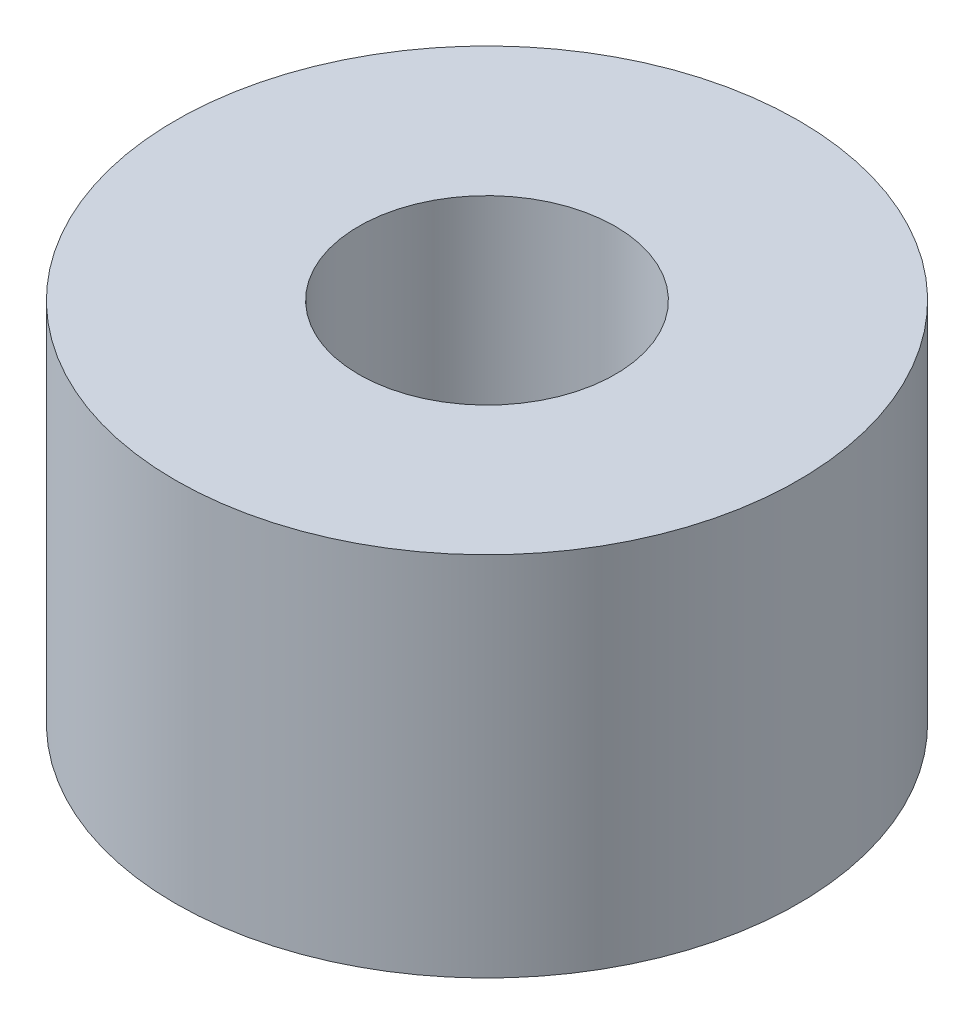
from build123d import *

# Parameters (mm, degrees)
SKETCH1_R           = 2.55
SKETCH1_R_2         = 1.05
BOSS_EXTRUDE1_DEPTH = 3


with BuildPart() as part:
    # Sketch1 → Boss-Extrude1 (new body)
    with BuildSketch(Plane(origin=(0, 0, 0), x_dir=(1, 0, 0), z_dir=(0, 1, 0))):
        Circle(SKETCH1_R)
        Circle(SKETCH1_R_2, mode=Mode.SUBTRACT)
    extrude(amount=BOSS_EXTRUDE1_DEPTH)


solid = part.part
